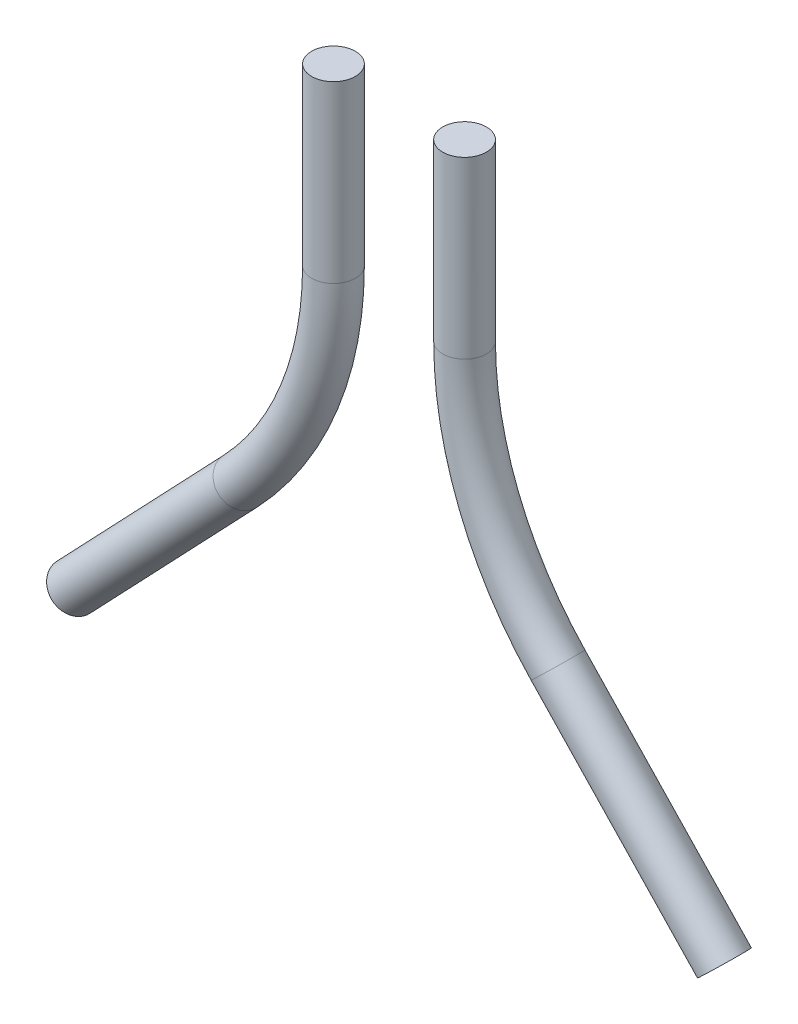
from build123d import *

# Parameters (mm, degrees)
SKETCH2_R = 0.25


with BuildPart() as part:
    # Sweep1: sweep along a path in Sketch1
    with BuildLine(Plane.XY) as sweep1_path:
        Line((3.904761905, -6.5), (2, -4.5))
        ThreePointArc((2, -4.5), (1.259271996, -3.346291202), (1, -2))
        Line((1, -2), (1, 0))
    # Sketch2 → Sweep1 (sweep)
    with BuildSketch(Plane(origin=(0, 0, 0), x_dir=(1, 0, 0), z_dir=(0, 1, 0))):
        with Locations((0.75, 0)):
            Circle(SKETCH2_R)
    sweep(path=sweep1_path.line)


with BuildPart() as body_2:
    # Mirror3: mirrored copy
    add(part.part.mirror(Plane(origin=(0, 0, 0), x_dir=(0, 0, 1), z_dir=(1, 0, 0))))


solid = Compound([part.part, body_2.part])
